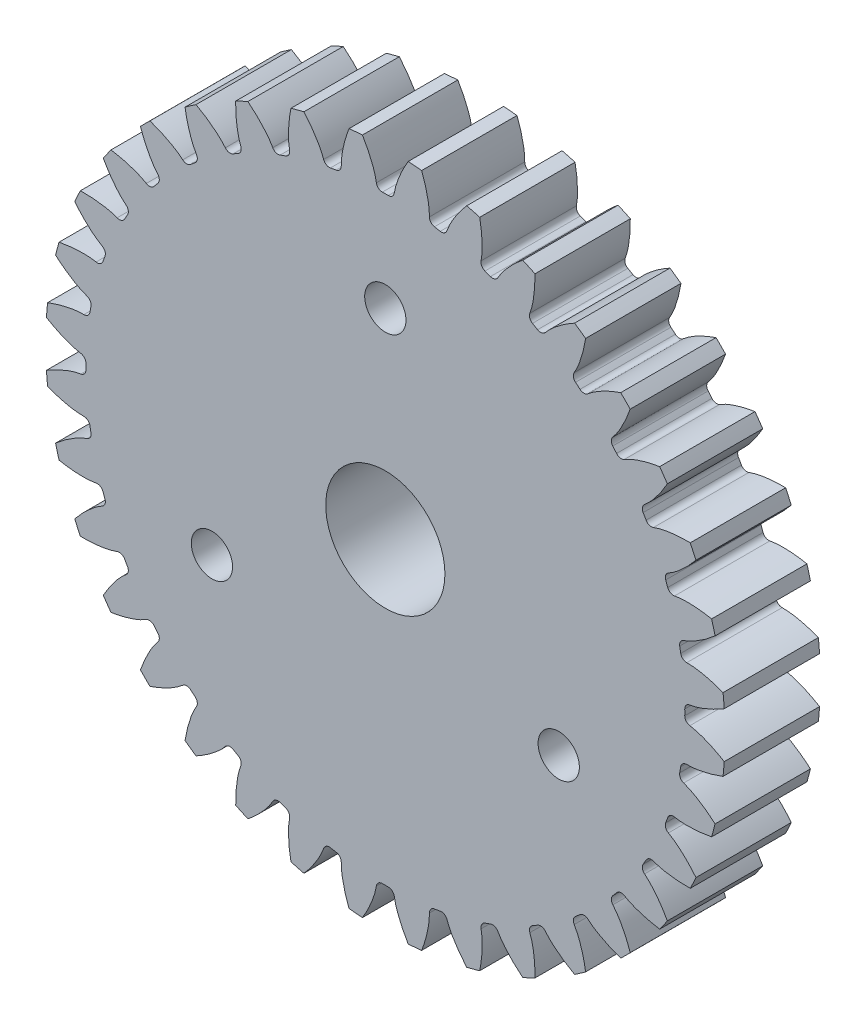
from build123d import *

# Parameters (mm, degrees)
SKETCH3_R                = 15.08125
BOSS_EXTRUDE1_DEPTH      = 2.116666667
BOSS_EXTRUDE1_DEPTH_BACK = 2.116666667
SKETCH5_W                = 11.1252
SKETCH5_H                = 2.645833333
CUT_EXTRUDE1_DEPTH       = 3.116666667
FILLET1_R                = 0.266307122
CIRPATTERN1_COUNT        = 36
FILLET1_OF_CIRPATTERN1_R = 0.266307122
SCALE1_SCALE             = 1.2
M2_CLEARANCE_HOLE1_D     = 2.2


with BuildPart() as part:
    # Sketch3 → Boss-Extrude1 (new body, two sides)
    with BuildSketch(Plane.XY) as boss_extrude1_sk:
        Circle(SKETCH3_R)
    extrude(amount=BOSS_EXTRUDE1_DEPTH)
    extrude(boss_extrude1_sk.sketch, amount=-BOSS_EXTRUDE1_DEPTH_BACK)

    # Sketch5 → Cut-Revolve1 (revolve, cut)
    with BuildSketch(Plane(origin=(0, 0, 0), x_dir=(0, 0, -1), z_dir=(1, 0, 0))):
        with Locations((0, 1.322916667)):
            Rectangle(SKETCH5_W, SKETCH5_H)
    revolve(axis=Axis((0, 0, 5.5626), (0, 0, -1)), mode=Mode.SUBTRACT)

    # Sketch4 → Cut-Extrude1 (cut, symmetric)
    with BuildSketch(Plane.XY):
        with BuildLine():
            Line((13.289826256, 0.381906465), (13.420318207, 0.38565638))
            add(Edge.make_bspline(
                [(13.420318207, 0.38565638), (13.422914897, 0.38575914), (13.430195068, 0.386134439), (13.443946597, 0.387187852), (13.466365456, 0.389395164), (13.494898024, 0.392925562), (13.531733888, 0.398312963), (13.575066094, 0.405719519), (13.622616226, 0.414969571), (13.67426481, 0.426231474), (13.725711415, 0.438526192), (13.776951293, 0.451776589), (13.827917483, 0.465864991), (13.889556653, 0.48398078), (13.963328411, 0.507162879), (14.049336344, 0.53638473), (14.14660985, 0.572034133), (14.245435829, 0.611046633), (14.342416431, 0.65163616), (14.44007817, 0.695175469), (14.534340064, 0.739093632), (14.63189425, 0.787299214), (14.721762066, 0.833111555), (14.822031607, 0.88729925), (14.90283031, 0.931864642), (14.985934696, 0.980284581), (15.026328374, 1.004202572), (15.046949136, 1.016574283)],
                knots=[0, 0, 0, 0, 0, 0.005376749, 0.015083688, 0.02853182, 0.04661014, 0.064854849, 0.092110526, 0.119476176, 0.146842496, 0.174208854, 0.201574956, 0.228941013, 0.256307345, 0.307035032, 0.361767352, 0.416499661, 0.471231937, 0.525964282, 0.580696616, 0.635428982, 0.690161387, 0.744893688, 0.799626082, 0.854358407, 0.909090914, 0.909090914, 0.909090914, 0.909090914, 0.909090914], degree=4))
            ThreePointArc((15.046949136, 1.016574283), (15.08125, 0), (15.046949136, -1.016574283))
            add(Edge.make_bspline(
                [(13.420318207, -0.38565638), (13.422914897, -0.38575914), (13.430195068, -0.386134439), (13.443946597, -0.387187852), (13.466365456, -0.389395164), (13.494898024, -0.392925562), (13.531733888, -0.398312963), (13.575066094, -0.405719519), (13.622616226, -0.414969571), (13.67426481, -0.426231474), (13.725711415, -0.438526192), (13.776951293, -0.451776589), (13.827917483, -0.465864991), (13.889556653, -0.48398078), (13.963328411, -0.507162879), (14.049336344, -0.53638473), (14.14660985, -0.572034133), (14.245435829, -0.611046633), (14.342416431, -0.65163616), (14.44007817, -0.695175469), (14.534340064, -0.739093632), (14.63189425, -0.787299214), (14.721762066, -0.833111555), (14.822031607, -0.88729925), (14.90283031, -0.931864642), (14.985934696, -0.980284581), (15.026328374, -1.004202572), (15.046949136, -1.016574283)],
                knots=[0, 0, 0, 0, 0, 0.005376749, 0.015083688, 0.02853182, 0.04661014, 0.064854849, 0.092110526, 0.119476176, 0.146842496, 0.174208854, 0.201574956, 0.228941013, 0.256307345, 0.307035032, 0.361767352, 0.416499661, 0.471231937, 0.525964282, 0.580696616, 0.635428982, 0.690161387, 0.744893688, 0.799626082, 0.854358407, 0.909090914, 0.909090914, 0.909090914, 0.909090914, 0.909090914], degree=4))
            Line((13.420318207, -0.38565638), (13.289826256, -0.381906465))
            ThreePointArc((13.289826256, -0.381906465), (13.2953125, 0), (13.289826256, 0.381906465))
        make_face()
    cut_extrude1 = extrude(amount=CUT_EXTRUDE1_DEPTH, both=True, mode=Mode.SUBTRACT)

    # Fillet1
    fillet1_edges = [part.edges().sort_by_distance(p)[0] for p in [
        (13.289826256, -0.381906465, 0),
        (13.289826256, 0.381906465, 0),
    ]]
    fillet(fillet1_edges, radius=FILLET1_R)

    # CirPattern1: Cut-Extrude1 ×36 about axis
    cirpattern1_axis = Axis((0, 0, 5.5626), (0, 0, -1))
    for i in range(1, CIRPATTERN1_COUNT):
        add(cut_extrude1.rotate(cirpattern1_axis, i * 360 / CIRPATTERN1_COUNT), mode=Mode.SUBTRACT)

    # Fillet1 of CirPattern1
    fillet1_of_cirpattern1_edges = [part.edges().sort_by_distance(p)[0] for p in [
        (13.021606572, -2.683858559, 0),
        (13.154241295, -1.931649663, 0),
        (12.357731961, -4.904262968, 0),
        (12.618971369, -4.186513594, 0),
        (11.318373917, -6.975653829, 0),
        (11.700280382, -6.314172428, 0),
        (9.93511281, -8.835092978, 0),
        (10.426082298, -8.249978327, 0),
        (8.249978327, -10.426082298, 0),
        (8.835092978, -9.93511281, 0),
        (6.314172428, -11.700280382, 0),
        (6.975653829, -11.318373917, 0),
        (4.186513594, -12.618971369, 0),
        (4.904262968, -12.357731961, 0),
        (1.931649663, -13.154241295, 0),
        (2.683858559, -13.021606572, 0),
        (-0.381906465, -13.289826256, 0),
        (0.381906465, -13.289826256, 0),
        (-2.683858559, -13.021606572, 0),
        (-1.931649663, -13.154241295, 0),
        (-4.904262968, -12.357731961, 0),
        (-4.186513594, -12.618971369, 0),
        (-6.975653829, -11.318373917, 0),
        (-6.314172428, -11.700280382, 0),
        (-8.835092978, -9.93511281, 0),
        (-8.249978327, -10.426082298, 0),
        (-10.426082298, -8.249978327, 0),
        (-9.93511281, -8.835092978, 0),
        (-11.700280382, -6.314172428, 0),
        (-11.318373917, -6.975653829, 0),
        (-12.618971369, -4.186513594, 0),
        (-12.357731961, -4.904262968, 0),
        (-13.154241295, -1.931649663, 0),
        (-13.021606572, -2.683858559, 0),
        (-13.289826256, 0.381906465, 0),
        (-13.289826256, -0.381906465, 0),
        (-13.021606572, 2.683858559, 0),
        (-13.154241295, 1.931649663, 0),
        (-12.357731961, 4.904262968, 0),
        (-12.618971369, 4.186513594, 0),
        (-11.318373917, 6.975653829, 0),
        (-11.700280382, 6.314172428, 0),
        (-9.93511281, 8.835092978, 0),
        (-10.426082298, 8.249978327, 0),
        (-8.249978327, 10.426082298, 0),
        (-8.835092978, 9.93511281, 0),
        (-6.314172428, 11.700280382, 0),
        (-6.975653829, 11.318373917, 0),
        (-4.186513594, 12.618971369, 0),
        (-4.904262968, 12.357731961, 0),
        (-1.931649663, 13.154241295, 0),
        (-2.683858559, 13.021606572, 0),
        (0.381906465, 13.289826256, 0),
        (-0.381906465, 13.289826256, 0),
        (2.683858559, 13.021606572, 0),
        (1.931649663, 13.154241295, 0),
        (4.904262968, 12.357731961, 0),
        (4.186513594, 12.618971369, 0),
        (6.975653829, 11.318373917, 0),
        (6.314172428, 11.700280382, 0),
        (8.835092978, 9.93511281, 0),
        (8.249978327, 10.426082298, 0),
        (10.426082298, 8.249978327, 0),
        (9.93511281, 8.835092978, 0),
        (11.700280382, 6.314172428, 0),
        (11.318373917, 6.975653829, 0),
        (12.618971369, 4.186513594, 0),
        (12.357731961, 4.904262968, 0),
        (13.154241295, 1.931649663, 0),
        (13.021606572, 2.683858559, 0),
    ]]
    fillet(fillet1_of_cirpattern1_edges, radius=FILLET1_OF_CIRPATTERN1_R)


with BuildPart() as part_1:
    # Scale1: scaled about (0, -1.3e-08, 0)
    add(part.part.scale(SCALE1_SCALE).moved(Location((0, 3e-09, 0))))

    # M2 Clearance Hole1 (through all)
    with Locations(Plane(origin=(0, 10.668, 2.54), x_dir=(1, 0, 0), z_dir=(0, 0, 1))):
        with Locations((0, 0), (-9.238759008, -16.002), (9.238759008, -16.002)):
            Hole(M2_CLEARANCE_HOLE1_D / 2)


solid = part_1.part
